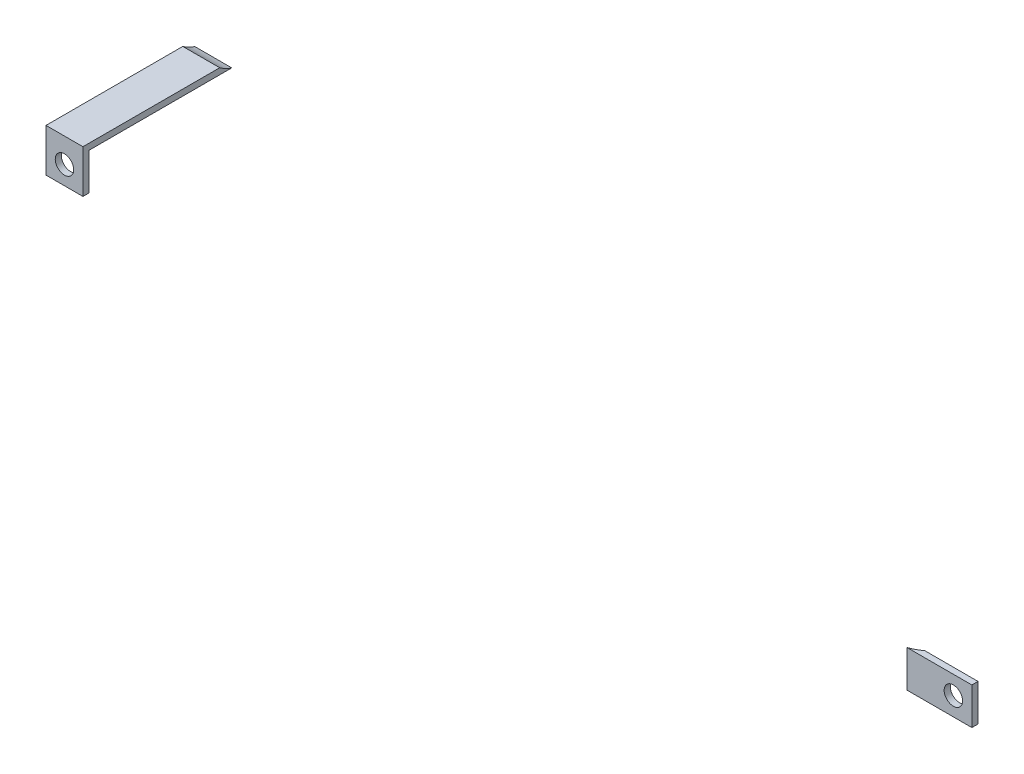
from build123d import *

# Parameters (mm, degrees)
DODANIE_WYCI_GNI_CIE2_DEPTH = 12
SZKIC3_R                    = 3
WYTNIJ_WYCI_GNI_CIE1_DEPTH  = 15
DODANIE_WYCI_GNI_CIE3_DEPTH = 12
SZKIC5_R                    = 3
WYTNIJ_WYCI_GNI_CIE2_DEPTH  = 12


with BuildPart() as part:
    # Szkic2 → Dodanie-wyciągnięcie2 (new body)
    with BuildSketch(Plane(origin=(0, 115, 0), x_dir=(-1, 0, 0), z_dir=(0, -1, 0))):
        with BuildLine():
            Line((-203.939898073, -111), (-225, -111))
            Line((-225, -111), (-225, -109))
            Line((-225, -109), (-207.685108725, -109))
            ThreePointArc((-207.685108725, -109), (-205.89804018, -110.160176633), (-203.939898073, -111))
        make_face()
    extrude(amount=-DODANIE_WYCI_GNI_CIE2_DEPTH)

    # Szkic3 → Wytnij-wyciągnięcie1 (cut)
    with BuildSketch(Plane(origin=(0, 0, 109), x_dir=(-1, 0, 0), z_dir=(0, 0, -1))):
        with Locations((-219, 121)):
            Circle(SZKIC3_R)
    extrude(amount=-WYTNIJ_WYCI_GNI_CIE1_DEPTH, mode=Mode.SUBTRACT)


with BuildPart() as body_2:
    # Szkic4 → Dodanie-wyciągnięcie3 (new body)
    with BuildSketch(Plane.ZY.offset(34.851954913)):
        with BuildLine():
            Line((107.553462494, 175.040321072), (152, 175.040321072))
            Line((152, 175.040321072), (152, 161.040321072))
            Line((152, 161.040321072), (150, 161.040321072))
            Line((150, 161.040321072), (150, 173.040321072))
            Line((150, 173.040321072), (103.63539268, 173.040321072))
            add(Edge.make_bspline(
                [(107.553462494, 175.040321072), (106.389921068, 174.157886349), (105.07331599, 173.477407712), (103.63539268, 173.040321072)],
                knots=[0.165921967, 0.165921967, 0.165921967, 0.165921967, 0.212843005, 0.212843005, 0.212843005, 0.212843005], degree=3, weights=[0.556552925, 0.535512773, 0.52034351, 0.511045138]))
        make_face()
    extrude(amount=-DODANIE_WYCI_GNI_CIE3_DEPTH)

    # Szkic5 → Wytnij-wyciągnięcie2 (cut)
    with BuildSketch(Plane(origin=(0, 0, 150), x_dir=(-1, 0, 0), z_dir=(0, 0, -1))):
        with Locations((28.851954913, 167.040321072)):
            Circle(SZKIC5_R)
    extrude(amount=-WYTNIJ_WYCI_GNI_CIE2_DEPTH, mode=Mode.SUBTRACT)


solid = Compound([part.part, body_2.part])
